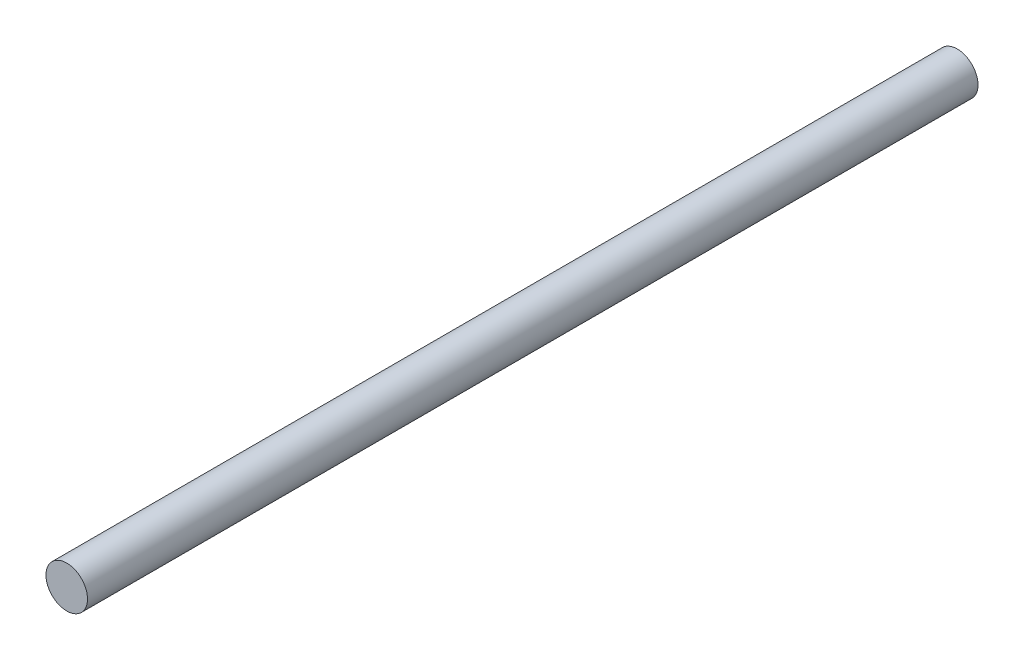
from build123d import *

# Parameters (mm, degrees)
SKETCH1_R           = 0.21
BOSS_EXTRUDE1_DEPTH = 9


with BuildPart() as part:
    # Sketch1 → Boss-Extrude1 (new body)
    with BuildSketch(Plane.XY):
        Circle(SKETCH1_R)
    extrude(amount=BOSS_EXTRUDE1_DEPTH)


solid = part.part
